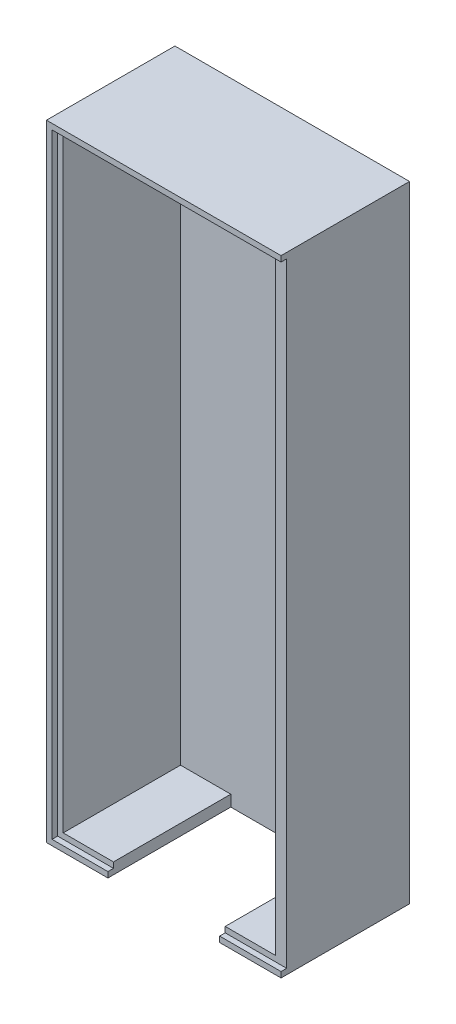
from build123d import *

# Parameters (mm, degrees)
SKETCH_1_W          = 40
SKETCH_1_H          = 110
EXTRUDE_1_DEPTH     = 22
SHELL_1_T           = -1
SKETCH_17_W         = 20
SKETCH_17_H         = 21
CUT_EXTRUDE_3_DEPTH = 2
SKETCH_2_W          = 23
SKETCH_2_H          = 110
EXTRUDE_2_DEPTH     = 1
SKETCH_3_W          = 41
SKETCH_3_H          = 23
EXTRUDE_3_DEPTH     = 1
SKETCH_18_W         = 20
SKETCH_18_H         = 22
CUT_EXTRUDE_4_DEPTH = 2
SKETCH_5_W          = 41
SKETCH_5_H          = 23
EXTRUDE_4_DEPTH     = 1
SKETCH_9_W          = 22
SKETCH_9_H          = 112
EXTRUDE_5_DEPTH     = 1
SKETCH_10_W         = 1
SKETCH_10_H         = 1
EXTRUDE_6_DEPTH     = 1
SKETCH_11_W         = 1
SKETCH_11_H         = 1
EXTRUDE_7_DEPTH     = 1


with BuildPart() as part:
    # 스케치1 → 보스-돌출1 (new body)
    with BuildSketch(Plane.XY):
        with Locations((20, 55)):
            Rectangle(SKETCH_1_W, SKETCH_1_H)
    extrude(amount=EXTRUDE_1_DEPTH)

    # 쉘1
    shell_1_openings = [part.faces().sort_by_distance(p)[0] for p in [
        (20, 55, 22),
    ]]
    offset(amount=SHELL_1_T, openings=shell_1_openings, kind=Kind.INTERSECTION)

    # 스케치17 → 컷-돌출3 (cut, through all)
    with BuildSketch(Plane(origin=(0, 1, 0), x_dir=(1, 0, 0), z_dir=(0, 1, 0))):
        with Locations((20, -11.5)):
            Rectangle(SKETCH_17_W, SKETCH_17_H)
    extrude(amount=-CUT_EXTRUDE_3_DEPTH, mode=Mode.SUBTRACT)

    # 스케치2 → 보스-돌출2 (add)
    with BuildSketch(Plane.ZY):
        with Locations((11.5, 55)):
            Rectangle(SKETCH_2_W, SKETCH_2_H)
    extrude(amount=EXTRUDE_2_DEPTH)

    # 스케치3 → 보스-돌출3 (add)
    with BuildSketch(Plane.XZ):
        with Locations((19.5, 11.5)):
            Rectangle(SKETCH_3_W, SKETCH_3_H)
    extrude(amount=EXTRUDE_3_DEPTH)

    # 스케치18 → 컷-돌출4 (cut, through all)
    with BuildSketch(Plane(origin=(0, 0, 0), x_dir=(1, 0, 0), z_dir=(0, 1, 0))):
        with Locations((20, -12)):
            Rectangle(SKETCH_18_W, SKETCH_18_H)
    extrude(amount=-CUT_EXTRUDE_4_DEPTH, mode=Mode.SUBTRACT)

    # 스케치5 → 보스-돌출4 (add)
    with BuildSketch(Plane(origin=(0, 110, 0), x_dir=(1, 0, 0), z_dir=(0, 1, 0))):
        with Locations((19.5, -11.5)):
            Rectangle(SKETCH_5_W, SKETCH_5_H)
    extrude(amount=EXTRUDE_4_DEPTH)

    # 스케치9 → 보스-돌출5 (add)
    with BuildSketch(Plane(origin=(40, 0, 0), x_dir=(0, 0, -1), z_dir=(1, 0, 0))):
        with Locations((-11, 55)):
            Rectangle(SKETCH_9_W, SKETCH_9_H)
    extrude(amount=EXTRUDE_5_DEPTH)

    # 스케치10 → 보스-돌출6 (add)
    with BuildSketch(Plane.XY.offset(22)):
        with Locations((40.5, 110.5)):
            Rectangle(SKETCH_10_W, SKETCH_10_H)
    extrude(amount=EXTRUDE_6_DEPTH)

    # 스케치11 → 보스-돌출7 (add)
    with BuildSketch(Plane.XY.offset(22)):
        with Locations((40.5, -0.5)):
            Rectangle(SKETCH_11_W, SKETCH_11_H)
    extrude(amount=EXTRUDE_7_DEPTH)


solid = part.part
